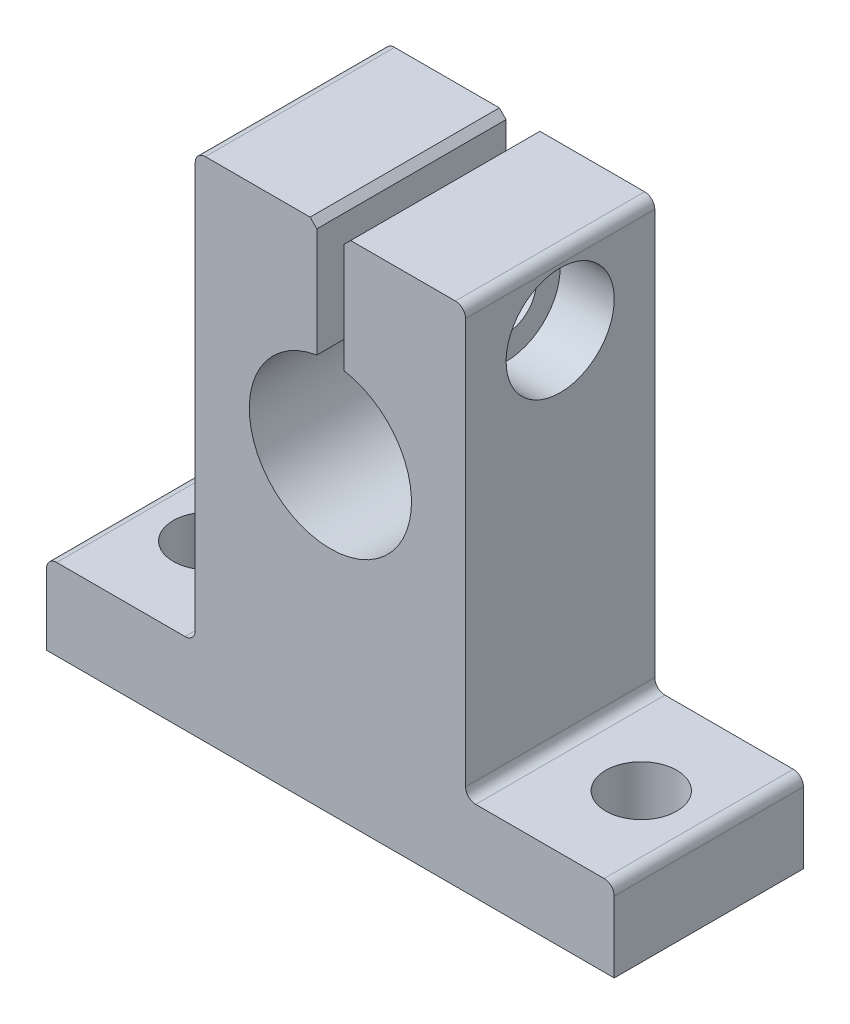
from build123d import *

# Parameters (mm, degrees)
SALIENTE_EXTRUIR1_DEPTH = 14
CROQUIS16_W             = 1.65
CROQUIS16_H             = 20
CORTAR_EXTRUIR3_REACH   = 8
CROQUIS4_R              = 2.625
REDONDEO0_75MM_R        = 0.75
CHAFL_N0_5MM_SIZE       = 0.5
CORTAR_EXTRUIR5_REACH   = 33
CROQUIS24_R             = 2.25
CROQUIS23_R             = 4
CORTAR_EXTRUIR4_DEPTH   = 4


with BuildPart() as part:
    # Croquis1 → Saliente-Extruir1 (new body)
    with BuildSketch(Plane.XY):
        with BuildLine():
            Line((-21, 6), (-21, 0))
            Line((-21, 0), (21, 0))
            Line((21, 0), (21, 6))
            Line((21, 6), (10, 6))
            Line((10, 6), (10, 37.5))
            Line((10, 37.5), (1, 37.5))
            Line((1, 37.5), (1, 28.916079783))
            ThreePointArc((1, 28.916079783), (0, 17), (-1, 28.916079783))
            Line((-1, 28.916079783), (-1, 37.5))
            Line((-1, 37.5), (-10, 37.5))
            Line((-10, 37.5), (-10, 6))
            Line((-10, 6), (-21, 6))
        make_face()
    extrude(amount=SALIENTE_EXTRUIR1_DEPTH)

    # Croquis16 → Taladro roscado M43 (revolve, cut)
    with BuildSketch(Plane(origin=(-1, 32.5, 7), x_dir=(0, 0, -1), z_dir=(0, 1, 0))):
        with Locations((0.825, 10)):
            Rectangle(CROQUIS16_W, CROQUIS16_H)
    revolve(axis=Axis((5.35, 32.5, 7), (-1, 0, 0)), mode=Mode.SUBTRACT)

    # Croquis4 → Cortar-Extruir3 (cut, up to next)
    with BuildSketch(Plane(origin=(0, 6, 0), x_dir=(1, 0, 0), z_dir=(0, 1, 0)), mode=Mode.PRIVATE) as cortar_extruir3_sk1:
        with Locations((-16, -7)):
            Circle(CROQUIS4_R)
    cortar_extruir3_tool1 = extrude(cortar_extruir3_sk1.sketch, amount=-CORTAR_EXTRUIR3_REACH, mode=Mode.PRIVATE) & part.part
    add(cortar_extruir3_tool1.solids().sort_by_distance((-16, 6, 7))[0], mode=Mode.SUBTRACT)
    # Croquis4 → Cortar-Extruir3 (cut, up to next)
    with BuildSketch(Plane(origin=(0, 6, 0), x_dir=(1, 0, 0), z_dir=(0, 1, 0)), mode=Mode.PRIVATE) as cortar_extruir3_sk2:
        with Locations((16, -7)):
            Circle(CROQUIS4_R)
    cortar_extruir3_tool2 = extrude(cortar_extruir3_sk2.sketch, amount=-CORTAR_EXTRUIR3_REACH, mode=Mode.PRIVATE) & part.part
    add(cortar_extruir3_tool2.solids().sort_by_distance((16, 6, 7))[0], mode=Mode.SUBTRACT)

    # Redondeo0,75mm
    redondeo0_75mm_edges = [part.edges().sort_by_distance(p)[0] for p in [
        (10, 37.5, 7),
        (10, 6, 7),
        (21, 6, 7),
        (-21, 6, 7),
        (-10, 6, 7),
        (-10, 37.5, 7),
    ]]
    fillet(redondeo0_75mm_edges, radius=REDONDEO0_75MM_R)

    # Chaflán0,5mm
    chafl_n0_5mm_edges = [part.edges().sort_by_distance(p)[0] for p in [
        (1, 37.5, 7),
        (-1, 37.5, 7),
    ]]
    chamfer(chafl_n0_5mm_edges, length=CHAFL_N0_5MM_SIZE)

    # Croquis24 → Cortar-Extruir5 (cut, up to next)
    with BuildSketch(Plane(origin=(10, 0, 0), x_dir=(0, 0, -1), z_dir=(1, 0, 0)), mode=Mode.PRIVATE) as cortar_extruir5_sk1:
        with Locations((-7, 32.5)):
            Circle(CROQUIS24_R)
    cortar_extruir5_tool1 = extrude(cortar_extruir5_sk1.sketch, amount=-CORTAR_EXTRUIR5_REACH, mode=Mode.PRIVATE) & part.part
    add(cortar_extruir5_tool1.solids().sort_by_distance((10, 32.5, 7))[0], mode=Mode.SUBTRACT)

    # Croquis23 → Cortar-Extruir4 (cut)
    with BuildSketch(Plane.ZY.offset(-10)):
        with Locations((7, 32.5)):
            Circle(CROQUIS23_R)
    extrude(amount=CORTAR_EXTRUIR4_DEPTH, mode=Mode.SUBTRACT)


solid = part.part
